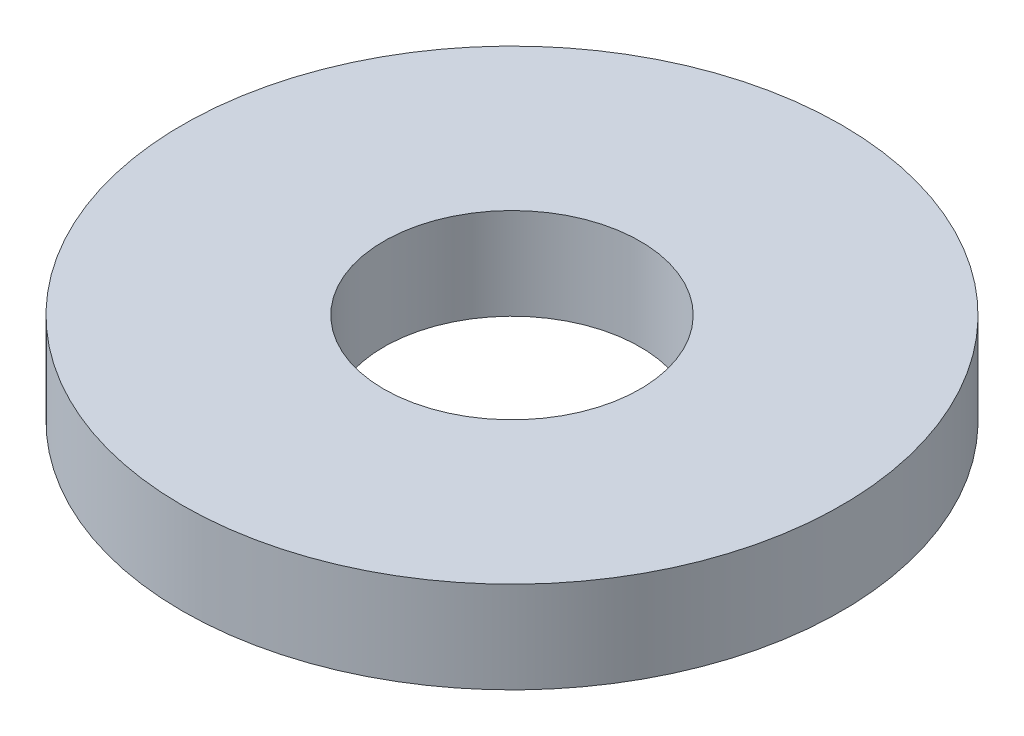
from build123d import *

# Parameters (mm, degrees)
SKETCH2_R           = 9
SKETCH2_R_2         = 3.5
BOSS_EXTRUDE1_DEPTH = 2.5


with BuildPart() as part:
    # Sketch2 → Boss-Extrude1 (new body)
    with BuildSketch(Plane(origin=(0, 0, 0), x_dir=(1, 0, 0), z_dir=(0, 1, 0))):
        Circle(SKETCH2_R)
        Circle(SKETCH2_R_2, mode=Mode.SUBTRACT)
    extrude(amount=BOSS_EXTRUDE1_DEPTH)


solid = part.part
